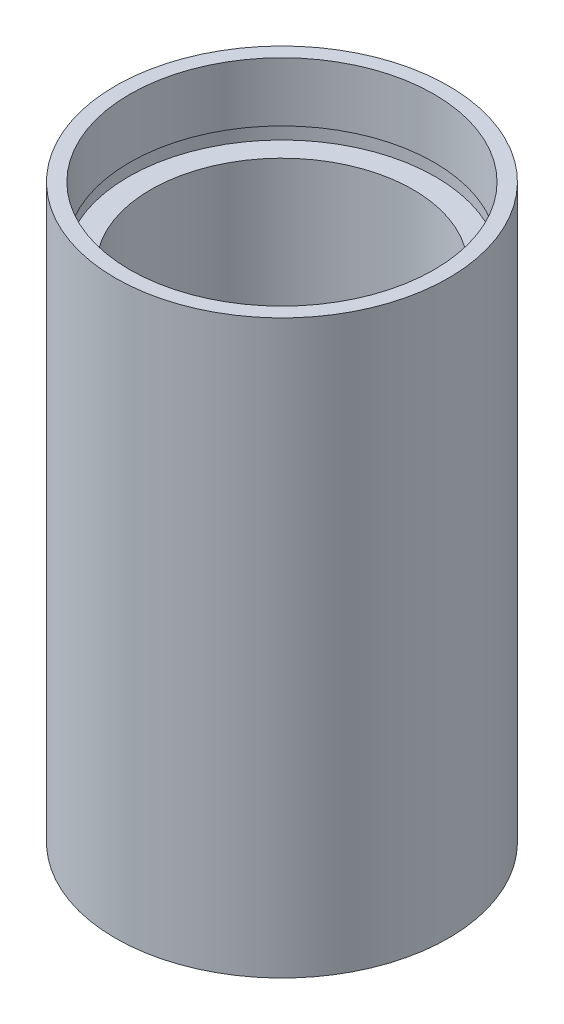
from build123d import *


with BuildPart() as part:
    # 草图1 → 旋转1 (revolve)
    with BuildSketch(Plane.XY, mode=Mode.PRIVATE) as revolve_1_sk:
        Polygon((11.1, 0), (11.1, 4.5), (11.7, 4.5), (11.7, 5.5), (10, 5.5), (10, 38.1), (11.7, 38.1), (11.7, 39.1), (11.6, 39.1), (11.6, 43.6), (12.7, 43.6), (12.7, 0), align=None)
    revolve(revolve_1_sk.sketch.rotate(Axis((0, 161.376166943, 0), (0, -1, 0)), 90), axis=Axis((0, 161.376166943, 0), (0, -1, 0)))  # turned: the seam where the file's is


solid = part.part
